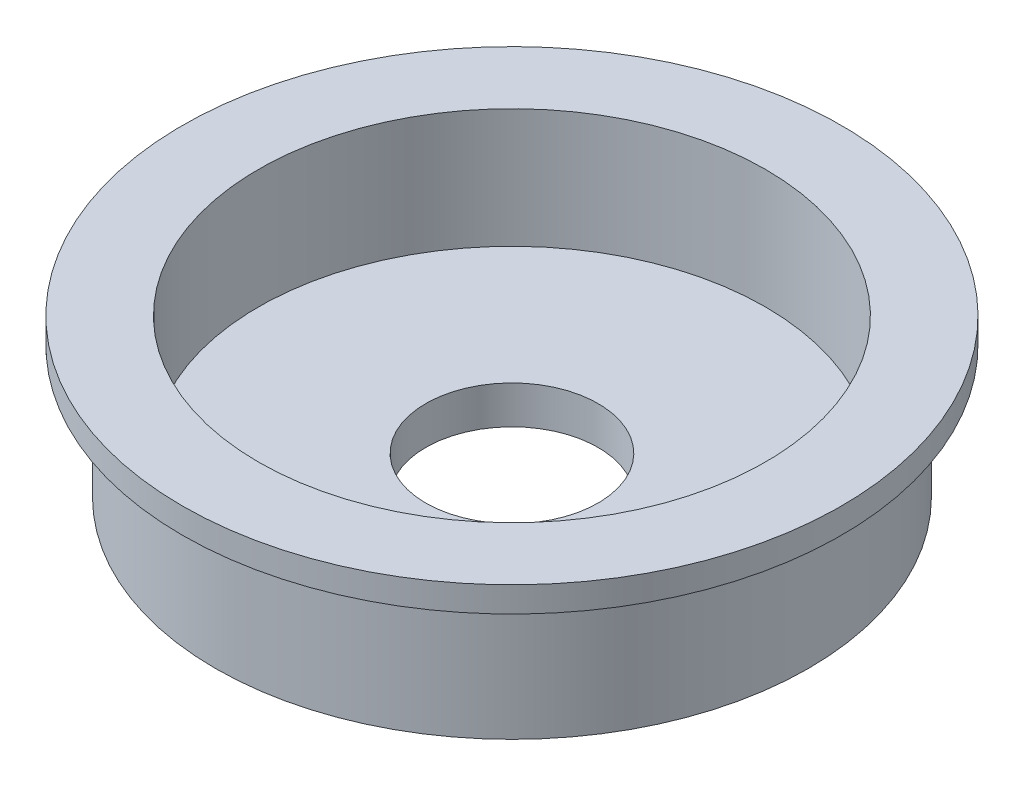
from build123d import *

# Parameters (mm, degrees)
SKETCH1_R           = 14.859
SKETCH1_R_2         = 4.318
BOSS_EXTRUDE1_DEPTH = 6.604
SKETCH2_R           = 16.51
SKETCH2_R_2         = 4.318
BOSS_EXTRUDE2_DEPTH = 1.27
SKETCH3_R           = 12.7
CUT_EXTRUDE1_DEPTH  = 5.969


with BuildPart() as part:
    # Sketch1 → Boss-Extrude1 (new body)
    with BuildSketch(Plane(origin=(0, 0, 0), x_dir=(1, 0, 0), z_dir=(0, 1, 0))):
        Circle(SKETCH1_R)
        Circle(SKETCH1_R_2, mode=Mode.SUBTRACT)
    extrude(amount=BOSS_EXTRUDE1_DEPTH)

    # Sketch2 → Boss-Extrude2 (add)
    with BuildSketch(Plane(origin=(0, 6.604, 0), x_dir=(1, 0, 0), z_dir=(0, 1, 0))):
        Circle(SKETCH2_R)
        Circle(SKETCH2_R_2, mode=Mode.SUBTRACT)
    extrude(amount=BOSS_EXTRUDE2_DEPTH)

    # Sketch3 → Cut-Extrude1 (cut)
    with BuildSketch(Plane(origin=(0, 7.874, 0), x_dir=(1, 0, 0), z_dir=(0, 1, 0))):
        Circle(SKETCH3_R)
    extrude(amount=-CUT_EXTRUDE1_DEPTH, mode=Mode.SUBTRACT)


solid = part.part
